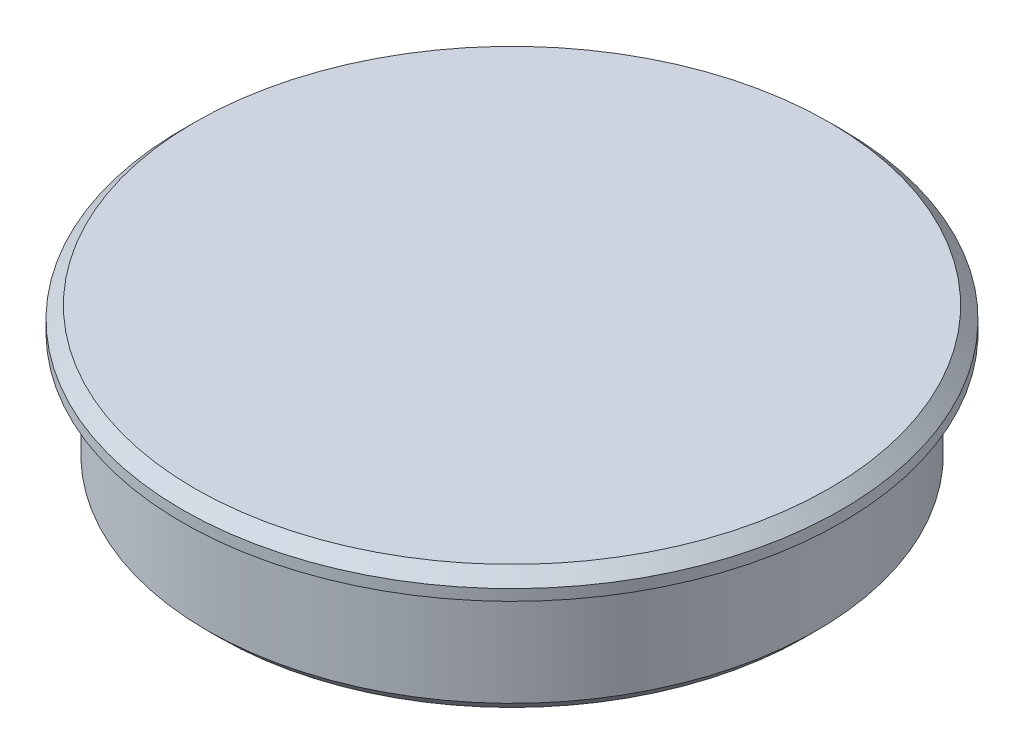
from build123d import *

# Parameters (mm, degrees)
CHAMFER1_SIZE = 0.5


with BuildPart() as part:
    # Sketch2 → Revolve1 (revolve)
    with BuildSketch(Plane.XY, mode=Mode.PRIVATE) as revolve1_sk:
        Polygon((12.4079, -3.75), (10.4079, -3.75), (10.4079, 0), (0, 0), (0, 2), (13.4079, 2), (13.4079, 1.05), (12.4079, 1.05), align=None)
    revolve(revolve1_sk.sketch.rotate(Axis((0, 0, 0), (0, 1, 0)), 90), axis=Axis((0, 0, 0), (0, 1, 0)))  # turned: the seam where the file's is

    # Chamfer1
    chamfer1_edges = [part.edges().sort_by_distance(p)[0] for p in [
        (0, -3.75, 12.4079),
        (0, 2, 13.4079),
    ]]
    chamfer(chamfer1_edges, length=CHAMFER1_SIZE)


solid = part.part
